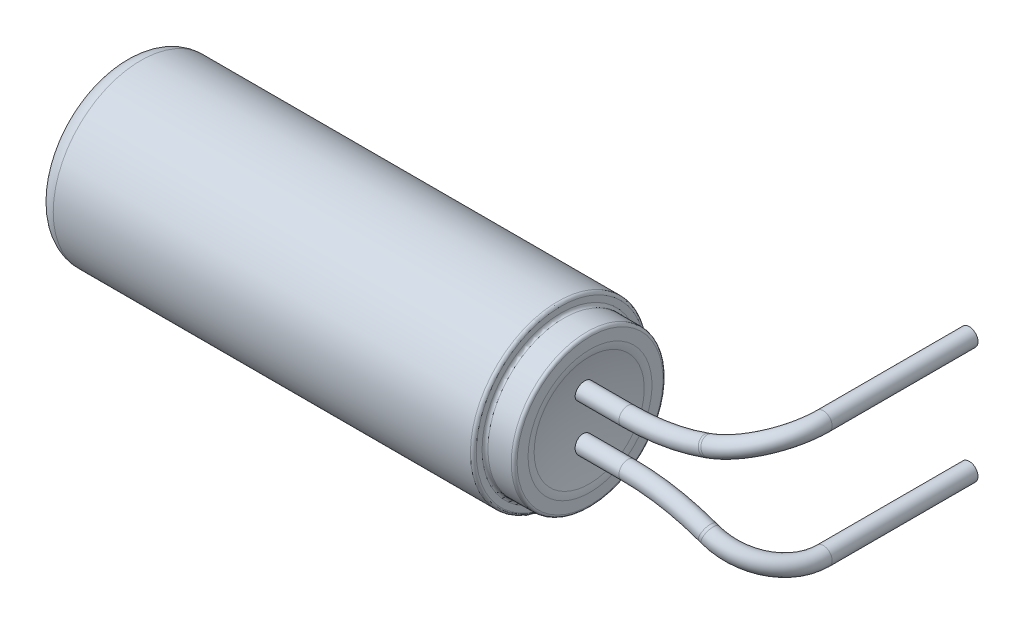
from build123d import *

# Parameters (mm, degrees)
SKETCH_2_R = 0.15


with BuildPart() as part:
    # Эскиз1 → Повернуть1 (revolve)
    with BuildSketch(Plane(origin=(0, 0, 0), x_dir=(1, 0, 0), z_dir=(0, 1, 0))):
        with BuildLine():
            Line((-3, -2.561610406), (-3, -2.75))
            ThreePointArc((-3, -2.75), (-3.014644661, -2.785355339), (-3.05, -2.8))
            Line((-3.05, -2.8), (-3.45, -2.8))
            ThreePointArc((-3.45, -2.8), (-3.485355339, -2.814644661), (-3.5, -2.85))
            Line((-3.5, -2.85), (-3.5, -2.95))
            ThreePointArc((-3.5, -2.95), (-3.514644661, -2.985355339), (-3.55, -3))
            Line((-3.55, -3), (-10.7, -3))
            ThreePointArc((-10.7, -3), (-10.912132034, -2.912132034), (-11, -2.7))
            Line((-11, -2.7), (-11, -1.5))
            Line((-11, -1.5), (-3.127016654, -1.5))
            ThreePointArc((-3.127016654, -1.5), (-3.098690434, -1.975191945), (-3.014112962, -2.443653694))
            ThreePointArc((-3.014112962, -2.443653694), (-3.003540777, -2.502211413), (-3, -2.561610406))
        make_face()
    revolve(axis=Axis((-1006.267886419, 0, 1.5), (1, 0, 0)))

    # По траектории1: sweep along a curve in space
    with BuildLine() as sweep_1_path:
        Line((-4, 0.4, 1.5), (-2.353794375, 0.4, 1.5))
        ThreePointArc((-0.985713801, 0.641229517, 1.5), (-1.659201664, 0.460768988, 1.5), (-2.353794375, 0.4, 1.5))
        Line((-0.939692621, 0.657979857, 1.5), (-0.985713801, 0.641229517, 1.5))
        ThreePointArc((-0.939692621, 0.657979857, 1.5), (-0.275229596, 0.899824619, 1.207106781), (0, 1, 0.5))
        Line((0, 1, -2), (0, 1, 0.5))
    # Эскиз2 → По траектории1 (sweep)
    with BuildSketch(Plane(origin=(-4, 0, 0), x_dir=(0, 0, -1), z_dir=(1, 0, 0))):
        with Locations((-1.5, 0.4)):
            Circle(SKETCH_2_R)
    sweep_1 = sweep(path=sweep_1_path.line)

    # Зеркальное отражение1: По траектории1 across plane
    add(sweep_1.mirror(Plane.ZX))


solid = part.part
